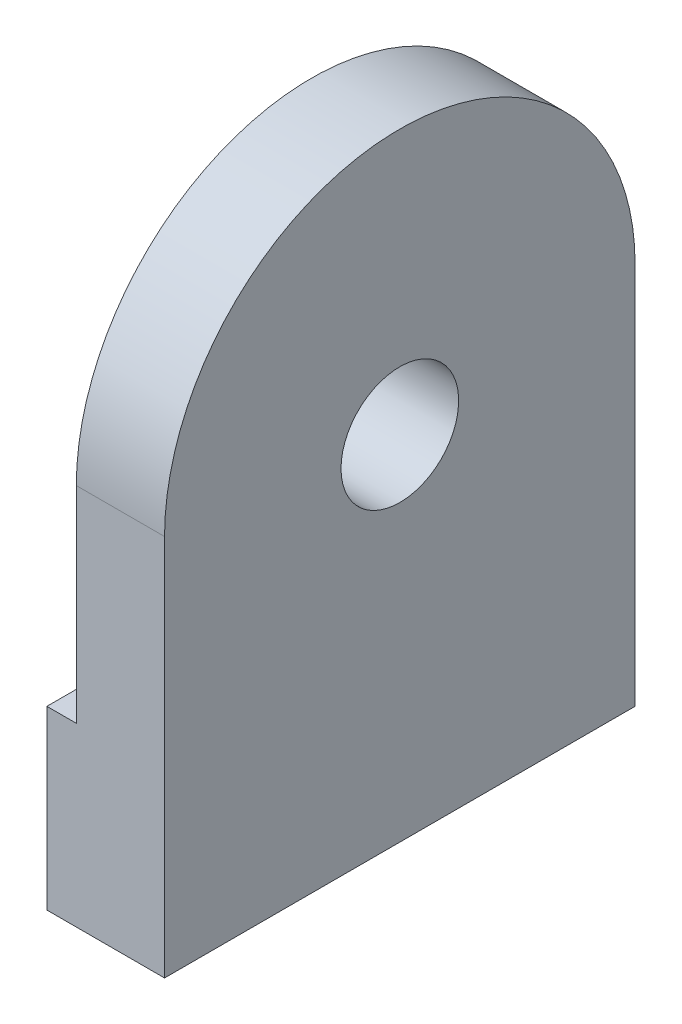
from build123d import *

# Parameters (mm, degrees)
BOSS_EXTRUDE1_DEPTH = 2
CUT_EXTRUDE1_DEPTH  = 0.5
SKETCH3_R           = 1
CUT_EXTRUDE2_DEPTH  = 2.5


with BuildPart() as part:
    # Sketch1 → Boss-Extrude1 (new body)
    with BuildSketch(Plane(origin=(0, 0, 0), x_dir=(0, 0, -1), z_dir=(1, 0, 0))):
        with BuildLine():
            Line((0, 0), (0, 6.5))
            ThreePointArc((0, 6.5), (4, 10.5), (8, 6.5))
            Line((8, 6.5), (8, 0))
            Line((8, 0), (0, 0))
        make_face()
    extrude(amount=BOSS_EXTRUDE1_DEPTH)

    # Sketch2 → Cut-Extrude1 (cut)
    with BuildSketch(Plane.ZY):
        with BuildLine():
            Line((-8, 3), (-6, 3))
            Line((-6, 3), (-6, 0))
            Line((-6, 0), (-2, 0))
            Line((-2, 0), (-2, 3))
            Line((-2, 3), (0, 3))
            Line((0, 3), (0, 6.5))
            ThreePointArc((0, 6.5), (-4, 10.5), (-8, 6.5))
            Line((-8, 6.5), (-8, 3))
        make_face()
    extrude(amount=-CUT_EXTRUDE1_DEPTH, mode=Mode.SUBTRACT)

    # Sketch3 → Cut-Extrude2 (cut, through all)
    with BuildSketch(Plane.ZY.offset(-0.5)):
        with Locations((-4, 6)):
            Circle(SKETCH3_R)
    extrude(amount=-CUT_EXTRUDE2_DEPTH, mode=Mode.SUBTRACT)


solid = part.part
